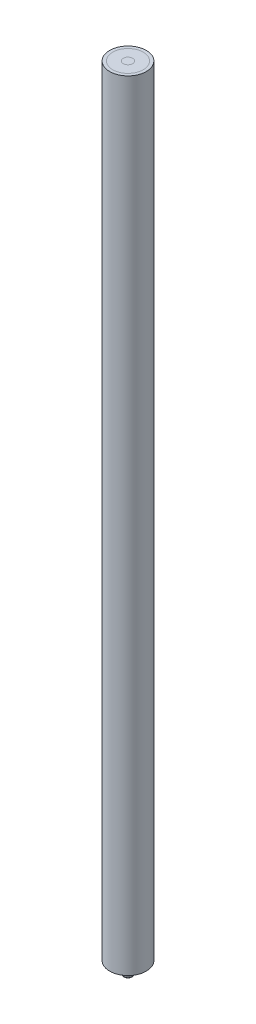
from build123d import *

# Parameters (mm, degrees)
SKETCH1_R                = 0.45974
BOSS_EXTRUDE1_DEPTH      = 76.2
BOSS_EXTRUDE1_DEPTH_BACK = 1.27
SKETCH2_R                = 1.49225
SKETCH2_R_2              = 0.45974
BOSS_EXTRUDE2_DEPTH      = 76.2
SKETCH3_R                = 1.7907
SKETCH3_R_2              = 1.49225
BOSS_EXTRUDE3_DEPTH      = 76.2
FILLET1_R                = 0.254


with BuildPart() as part:
    # Sketch1 → Boss-Extrude1 (new body, two sides)
    with BuildSketch(Plane(origin=(0, 0, 0), x_dir=(1, 0, 0), z_dir=(0, 1, 0))) as boss_extrude1_sk:
        Circle(SKETCH1_R)
    extrude(amount=BOSS_EXTRUDE1_DEPTH)
    extrude(boss_extrude1_sk.sketch, amount=-BOSS_EXTRUDE1_DEPTH_BACK)

    # Fillet1
    fillet1_edges = [part.edges().sort_by_distance(p)[0] for p in [
        (-0.45974, -1.27, 0),
    ]]
    fillet(fillet1_edges, radius=FILLET1_R)


with BuildPart() as body_2:
    # Sketch2 → Boss-Extrude2 (new body)
    with BuildSketch(Plane(origin=(0, 0, 0), x_dir=(1, 0, 0), z_dir=(0, 1, 0))):
        Circle(SKETCH2_R)
        Circle(SKETCH2_R_2, mode=Mode.SUBTRACT)
    extrude(amount=BOSS_EXTRUDE2_DEPTH)


with BuildPart() as body_3:
    # Sketch3 → Boss-Extrude3 (new body)
    with BuildSketch(Plane(origin=(0, 0, 0), x_dir=(1, 0, 0), z_dir=(0, 1, 0))):
        Circle(SKETCH3_R)
        Circle(SKETCH3_R_2, mode=Mode.SUBTRACT)
    extrude(amount=BOSS_EXTRUDE3_DEPTH)


solid = Compound([part.part, body_2.part, body_3.part])
